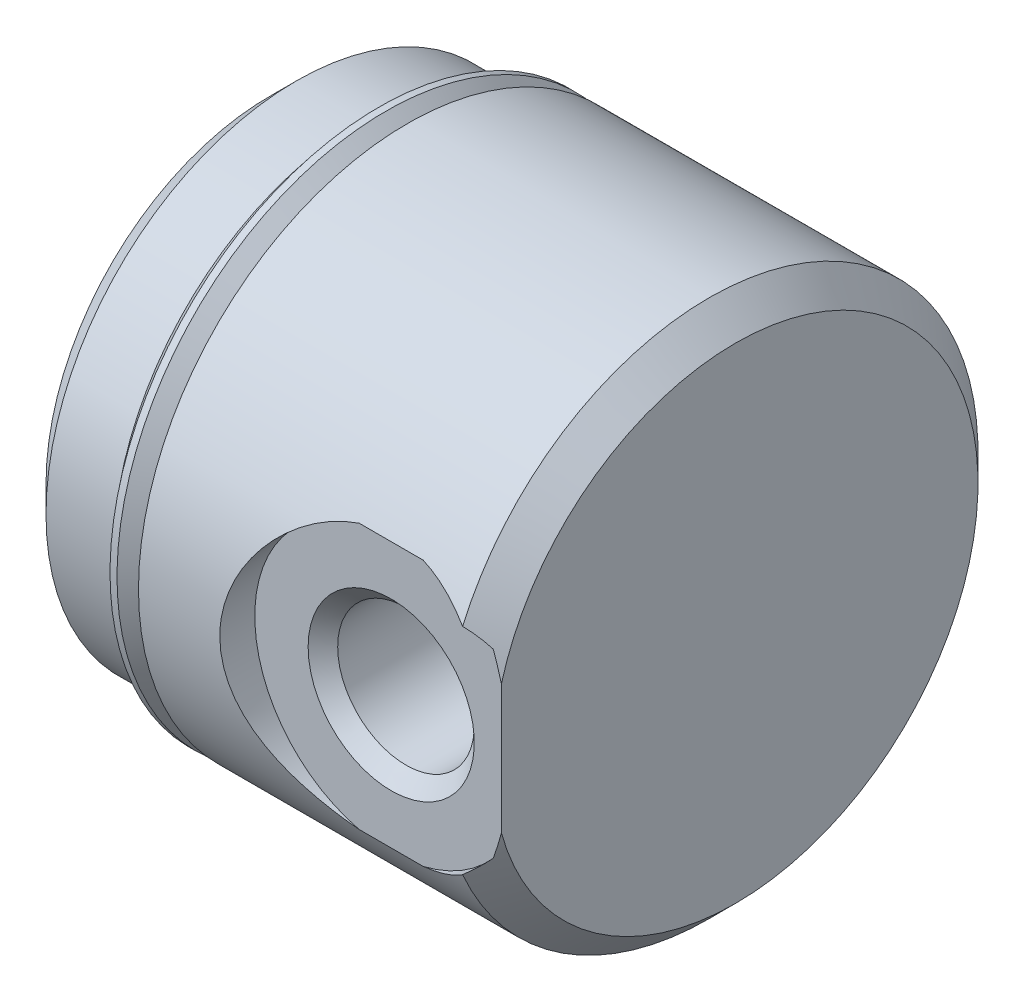
from build123d import *


with BuildPart() as part:
    # Sketch1 → Revolve1 (revolve)
    with BuildSketch(Plane.XY):
        Polygon((0, 0), (0, 6.50875), (0.762, 7.27075), (2.7178, 7.27075), (3.3528, 6.63575), (3.9878, 6.63575), (3.9878, 7.8105), (12.7508, 7.8105), (13.5128, 7.0485), (13.5128, 0), align=None)
    revolve(axis=Axis((13.5128, 0, 0), (-1, 0, 0)))

    # Sketch2 → Cut-Revolve1 (revolve, cut)
    with BuildSketch(Plane.XY):
        Polygon((0, 0), (0, 1.9558), (12.2936, 1.9558), (13.422781656, 0), align=None)
    revolve(axis=Axis((13.422781656, 0, 0), (-1, 0, 0)), mode=Mode.SUBTRACT)

    # Sketch3 → Cut-Revolve2 (revolve, cut)
    with BuildSketch(Plane(origin=(0, 0, 0), x_dir=(1, 0, 0), z_dir=(0, 1, 0))):
        Polygon((10.3124, 0), (12.29614, 0), (12.29614, -6.36524), (12.7254, -6.7945), (14.2748, -6.7945), (14.2748, -7.8105), (10.3124, -7.8105), align=None)
    revolve(axis=Axis((10.3124, 0, 7.8105), (0, 0, -1)), mode=Mode.SUBTRACT)

    # Sketch4 → Revolve2 (revolve)
    with BuildSketch(Plane.XY):
        with BuildLine():
            Line((3.160243808, 7.8105), (3.160243808, 7.726331804))
            Line((3.160243808, 7.726331804), (3.870760245, 7.015815367))
            ThreePointArc((3.870760245, 7.015815367), (3.907957684, 6.926012806), (3.870760245, 6.836210245))
            Line((3.870760245, 6.836210245), (3.6703, 6.63575))
            Line((3.6703, 6.63575), (3.3528, 6.63575))
            Line((3.3528, 6.63575), (3.3528, 6.38175))
            Line((3.3528, 6.38175), (3.9878, 6.38175))
            Line((3.9878, 6.38175), (3.9878, 7.186143808))
            Line((3.9878, 7.186143808), (3.363443808, 7.8105))
            Line((3.363443808, 7.8105), (3.160243808, 7.8105))
        make_face()
    revolve(axis=Axis((3.9878, 0, 0), (-1, 0, 0)))


solid = part.part
